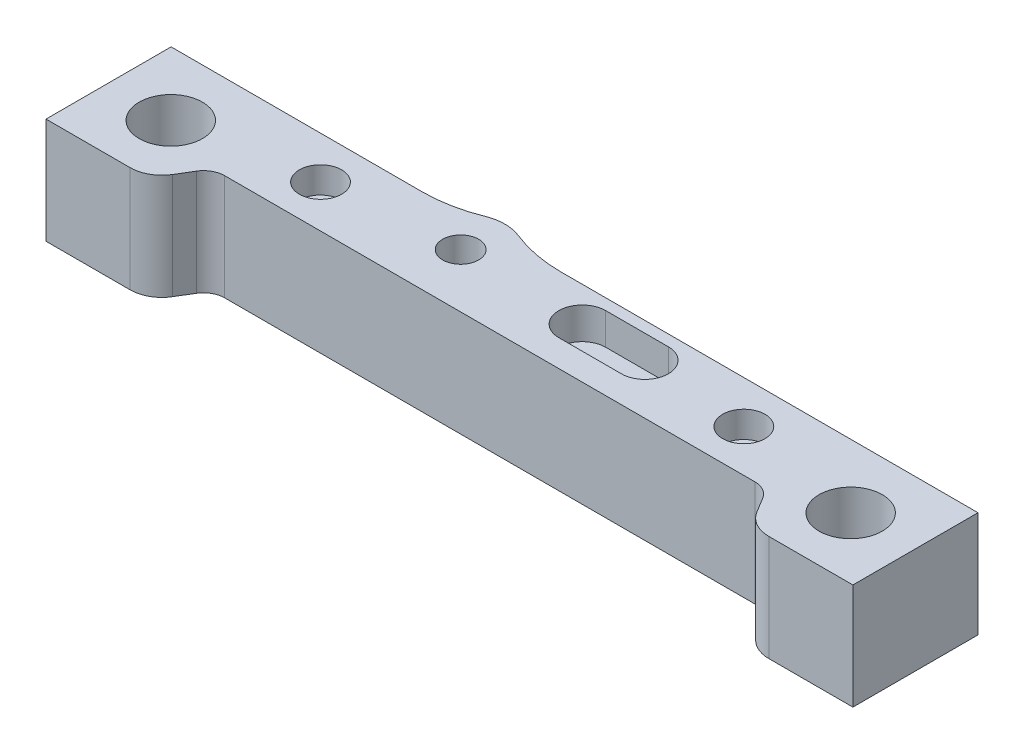
from build123d import *

# Parameters (mm, degrees)
SKETCH1_R           = 2
SKETCH1_R_2         = 2.99
SKETCH1_R_3         = 1.7
BOSS_EXTRUDE1_DEPTH = 10
FILLET1_R           = 2
FILLET2_R           = 3
SKETCH1_4_R         = 2.99
CUT_EXTRUDE3_DEPTH  = 5.07
SKETCH1_5_R         = 2
CUT_EXTRUDE4_DEPTH  = 2.48
CUT_EXTRUDE5_DEPTH  = 3
SKETCH1_7_R         = 1.7
CUT_EXTRUDE6_DEPTH  = 10
SKETCH4_R           = 1.25
CUT_EXTRUDE7_DEPTH  = 10
SKETCH5_R           = 2.725
CUT_EXTRUDE8_DEPTH  = 2.8


with BuildPart() as part:
    # Sketch1 → Boss-Extrude1 (new body)
    with BuildSketch(Plane(origin=(0, 0, 0), x_dir=(1, 0, 0), z_dir=(0, 1, 0))):
        with BuildLine():
            ThreePointArc((-9.409245094, 8.977987014), (-7.849239736, 9.28), (-6.289234378, 8.977987014))
            ThreePointArc((-6.289234378, 8.977987014), (-3.835653376, 8.254222737), (-1.289234378, 8.01))
            Line((-1.289234378, 8.01), (38.12, 8.01))
            Line((38.12, 8.01), (38.12, -3.81))
            Line((38.12, -3.81), (28.478275237, -3.81))
            Line((28.478275237, -3.81), (26.178275237, 0))
            Line((26.178275237, 0), (-26.178275237, 0))
            Line((-26.178275237, 0), (-28.478275237, -3.81))
            Line((-28.478275237, -3.81), (-38.12, -3.81))
            Line((-38.12, -3.81), (-38.12, 8.01))
            Line((-38.12, 8.01), (-14.409245094, 8.01))
            ThreePointArc((-14.409245094, 8.01), (-11.862826096, 8.254222737), (-9.409245094, 8.977987014))
        make_face()
        with Locations((20, 4.005)):
            Circle(SKETCH1_R, mode=Mode.SUBTRACT)
        with Locations((-20, 4.005)):
            Circle(SKETCH1_R, mode=Mode.SUBTRACT)
        with Locations((-32.12, 1.98)):
            Circle(SKETCH1_R_2, mode=Mode.SUBTRACT)
        with Locations((32.12, 1.98)):
            Circle(SKETCH1_R_2, mode=Mode.SUBTRACT)
        with Locations((-7.849239736, 5.1)):
            Circle(SKETCH1_R_3, mode=Mode.SUBTRACT)
        with BuildLine():
            ThreePointArc((9.912105026, 2.53), (12.127105026, 4.745), (9.912105026, 6.96))
            Line((9.912105026, 6.96), (3.992105026, 6.96))
            ThreePointArc((3.992105026, 6.96), (1.777105026, 4.745), (3.992105026, 2.53))
            Line((3.992105026, 2.53), (9.912105026, 2.53))
        make_face(mode=Mode.SUBTRACT)
        with Locations((-20, 4.005)):
            Circle(SKETCH1_R)
        with Locations((-7.849239736, 5.1)):
            Circle(SKETCH1_R_3)
        with Locations((-32.12, 1.98)):
            Circle(SKETCH1_R_2)
        with BuildLine():
            Line((3.992105026, 2.53), (9.912105026, 2.53))
            ThreePointArc((9.912105026, 2.53), (12.127105026, 4.745), (9.912105026, 6.96))
            Line((9.912105026, 6.96), (3.992105026, 6.96))
            ThreePointArc((3.992105026, 6.96), (1.777105026, 4.745), (3.992105026, 2.53))
        make_face()
        with Locations((20, 4.005)):
            Circle(SKETCH1_R)
        with Locations((32.12, 1.98)):
            Circle(SKETCH1_R_2)
    extrude(amount=-BOSS_EXTRUDE1_DEPTH)

    # Fillet1
    fillet1_edges = [part.edges().sort_by_distance(p)[0] for p in [
        (26.178275237, -5, 0),
        (-26.178275237, -5, 0),
    ]]
    fillet(fillet1_edges, radius=FILLET1_R)

    # Fillet2
    fillet2_edges = [part.edges().sort_by_distance(p)[0] for p in [
        (28.478275237, -5, 3.81),
        (-28.478275237, -5, 3.81),
    ]]
    fillet(fillet2_edges, radius=FILLET2_R)

    # Sketch1_4 → Cut-Extrude3 (cut)
    with BuildSketch(Plane(origin=(0, 0, 0), x_dir=(1, 0, 0), z_dir=(0, 1, 0))):
        with Locations((32.12, 1.98)):
            Circle(SKETCH1_4_R)
        with Locations((-32.12, 1.98)):
            Circle(SKETCH1_4_R)
    extrude(amount=-CUT_EXTRUDE3_DEPTH, mode=Mode.SUBTRACT)

    # Sketch1_5 → Cut-Extrude4 (cut)
    with BuildSketch(Plane(origin=(0, 0, 0), x_dir=(1, 0, 0), z_dir=(0, 1, 0))):
        with Locations((-20, 4.005)):
            Circle(SKETCH1_5_R)
        with Locations((20, 4.005)):
            Circle(SKETCH1_5_R)
    extrude(amount=-CUT_EXTRUDE4_DEPTH, mode=Mode.SUBTRACT)

    # Sketch1_6 → Cut-Extrude5 (cut)
    with BuildSketch(Plane(origin=(0, 0, 0), x_dir=(1, 0, 0), z_dir=(0, 1, 0))):
        with BuildLine():
            Line((3.992105026, 2.53), (9.912105026, 2.53))
            ThreePointArc((9.912105026, 2.53), (12.127105026, 4.745), (9.912105026, 6.96))
            Line((9.912105026, 6.96), (3.992105026, 6.96))
            ThreePointArc((3.992105026, 6.96), (1.777105026, 4.745), (3.992105026, 2.53))
        make_face()
    extrude(amount=-CUT_EXTRUDE5_DEPTH, mode=Mode.SUBTRACT)

    # Sketch1_7 → Cut-Extrude6 (cut)
    with BuildSketch(Plane(origin=(0, 0, 0), x_dir=(1, 0, 0), z_dir=(0, 1, 0))):
        with Locations((-7.849239736, 5.1)):
            Circle(SKETCH1_7_R)
    extrude(amount=-CUT_EXTRUDE6_DEPTH, mode=Mode.SUBTRACT)

    # Sketch4 → Cut-Extrude7 (cut)
    with BuildSketch(Plane(origin=(0, 0, 0), x_dir=(1, 0, 0), z_dir=(0, 1, 0))):
        with Locations((-20, 4.005)):
            Circle(SKETCH4_R)
        with Locations((20, 4.005)):
            Circle(SKETCH4_R)
    extrude(amount=-CUT_EXTRUDE7_DEPTH, mode=Mode.SUBTRACT)

    # Sketch5 → Cut-Extrude8 (cut)
    with BuildSketch(Plane.XZ.offset(10)):
        with Locations((20, -4.005)):
            Circle(SKETCH5_R)
        with Locations((-20, -4.005)):
            Circle(SKETCH5_R)
    extrude(amount=-CUT_EXTRUDE8_DEPTH, mode=Mode.SUBTRACT)


solid = part.part
